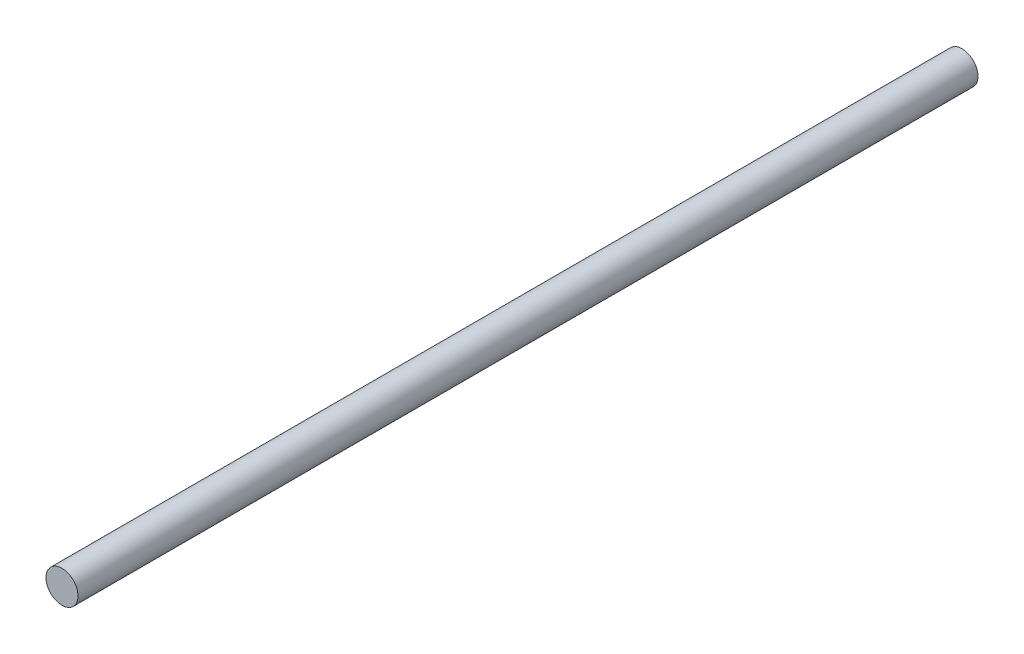
from build123d import *

# Parameters (mm, degrees)
SKETCH1_R           = 4.45
BOSS_EXTRUDE1_DEPTH = 250


with BuildPart() as part:
    # Sketch1 → Boss-Extrude1 (new body)
    with BuildSketch(Plane.XY):
        Circle(SKETCH1_R)
    extrude(amount=BOSS_EXTRUDE1_DEPTH)


solid = part.part
